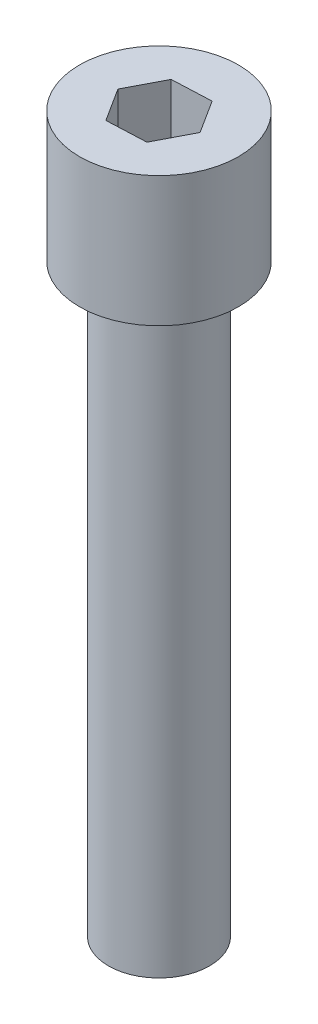
from build123d import *

# Parameters (mm, degrees)
ESBO_O1_R                = 3.5
RESSALTO_EXTRUS_O1_DEPTH = 40.5
ESBO_O2_R                = 5.5
RESSALTO_EXTRUS_O2_DEPTH = 9
CORTE_EXTRUS_O1_DEPTH    = 5


with BuildPart() as part:
    # Esboço1 → Ressalto-extrusão1 (new body)
    with BuildSketch(Plane(origin=(0, 0, 0), x_dir=(1, 0, 0), z_dir=(0, 1, 0))):
        Circle(ESBO_O1_R)
    extrude(amount=RESSALTO_EXTRUS_O1_DEPTH)

    # Esboço2 → Ressalto-extrusão2 (add)
    with BuildSketch(Plane(origin=(0, 40.5, 0), x_dir=(1, 0, 0), z_dir=(0, 1, 0))):
        Circle(ESBO_O2_R)
    extrude(amount=RESSALTO_EXTRUS_O2_DEPTH)

    # Esboço3 → Corte-extrusão1 (cut)
    with BuildSketch(Plane(origin=(0, 49.5, 0), x_dir=(1, 0, 0), z_dir=(0, 1, 0))):
        Polygon((1.258537272, 2.417896859), (-1.464691468, 2.298873679), (-2.72322874, -0.11902318), (-1.258537272, -2.417896859), (1.464691468, -2.298873679), (2.72322874, 0.11902318), align=None)
    extrude(amount=-CORTE_EXTRUS_O1_DEPTH, mode=Mode.SUBTRACT)


solid = part.part
